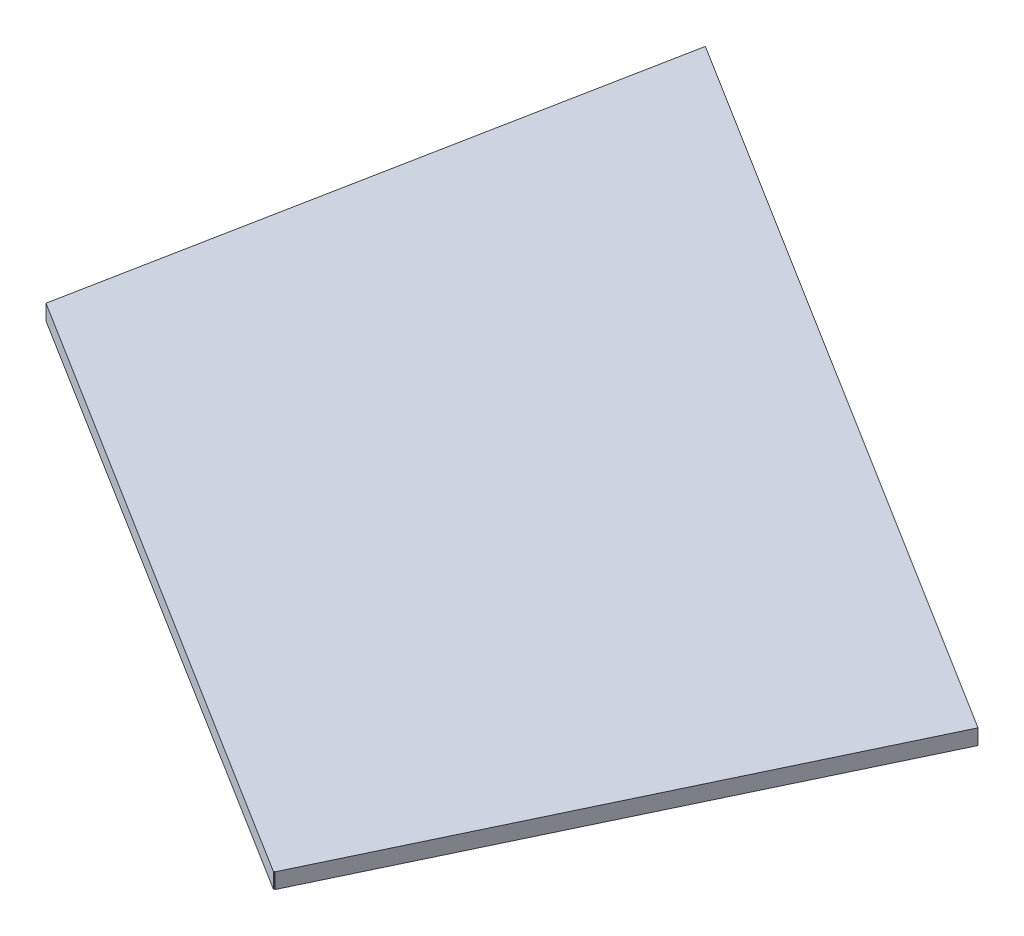
from build123d import *

# Parameters (mm, degrees)
BOSS_EXTRU_1_DEPTH = 2


with BuildPart() as part:
    # Esquisse1 → Boss.-Extru.1 (new body)
    with BuildSketch(Plane(origin=(0, 0, 0), x_dir=(1, 0, 0), z_dir=(0, 1, 0))):
        Polygon((78.882422148, -49.280599365), (78.932345002, -49.168232372), (79.021674184, -49.223945823), (108.555181003, 12.793072358), (13.970386351, 71.883491293), (0, 0), align=None)
    extrude(amount=BOSS_EXTRU_1_DEPTH)


solid = part.part
